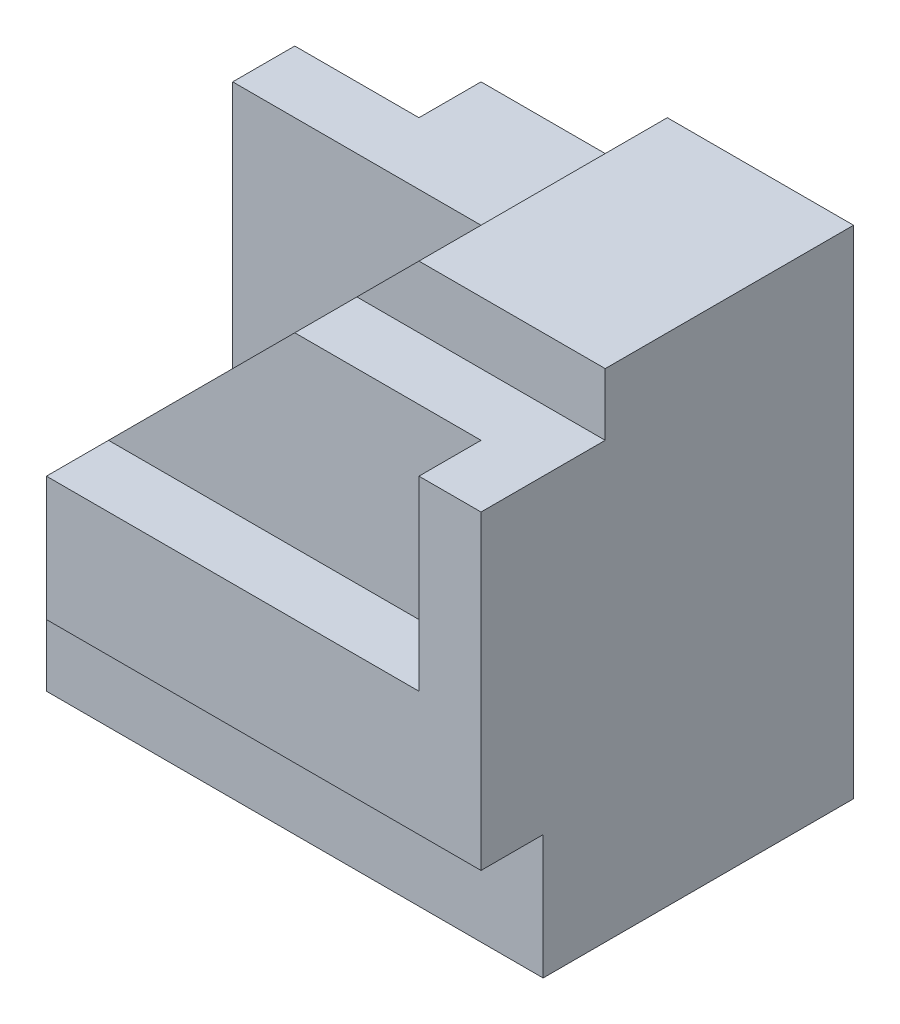
from build123d import *

# Parameters (mm, degrees)
SKETCH1_W           = 8
SKETCH1_H           = 6
BOSS_EXTRUDE1_DEPTH = 8
SKETCH2_W           = 1
SKETCH2_H           = 2
CUT_EXTRUDE1_DEPTH  = 9
SKETCH3_W           = 7
SKETCH3_H           = 4
CUT_EXTRUDE2_DEPTH  = 1
SKETCH4_W           = 3
SKETCH4_H           = 1
CUT_EXTRUDE3_DEPTH  = 2
CUT_EXTRUDE4_DEPTH  = 3
SKETCH8_W           = 1
SKETCH8_H           = 1
CUT_EXTRUDE7_DEPTH  = 1
CUT_EXTRUDE8_DEPTH  = 3
CUT_EXTRUDE9_DEPTH  = 1
SKETCH14_W          = 4
SKETCH14_H          = 2
CUT_EXTRUDE12_DEPTH = 1
BOSS_EXTRUDE2_DEPTH = 1
SKETCH16_W          = 1
SKETCH16_H          = 1
CUT_EXTRUDE13_DEPTH = 5
CUT_EXTRUDE14_DEPTH = 1


with BuildPart() as part:
    # Sketch1 → Boss-Extrude1 (new body)
    with BuildSketch(Plane(origin=(0, 0, 0), x_dir=(1, 0, 0), z_dir=(0, 1, 0))):
        Rectangle(SKETCH1_W, SKETCH1_H)
    extrude(amount=BOSS_EXTRUDE1_DEPTH)

    # Sketch2 → Cut-Extrude1 (cut, through all)
    with BuildSketch(Plane.ZY.offset(4)):
        with Locations((2.5, 1)):
            Rectangle(SKETCH2_W, SKETCH2_H)
    extrude(amount=-CUT_EXTRUDE1_DEPTH, mode=Mode.SUBTRACT)

    # Sketch3 → Cut-Extrude2 (cut)
    with BuildSketch(Plane.XY.offset(3)):
        with Locations((-0.5, 6)):
            Rectangle(SKETCH3_W, SKETCH3_H)
    extrude(amount=-CUT_EXTRUDE2_DEPTH, mode=Mode.SUBTRACT)

    # Sketch4 → Cut-Extrude3 (cut)
    with BuildSketch(Plane.XY.offset(3)):
        with Locations((2.5, 7.5)):
            Rectangle(SKETCH4_W, SKETCH4_H)
    extrude(amount=-CUT_EXTRUDE3_DEPTH, mode=Mode.SUBTRACT)

    # Sketch5 → Cut-Extrude4 (cut)
    with BuildSketch(Plane.XY.offset(2)):
        Polygon((1, 8), (-3, 4), (-4, 4), (-4, 8), align=None)
    extrude(amount=-CUT_EXTRUDE4_DEPTH, mode=Mode.SUBTRACT)

    # Sketch8 → Cut-Extrude7 (cut)
    with BuildSketch(Plane(origin=(1, 0, 0), x_dir=(0, 0, -1), z_dir=(1, 0, 0))):
        with Locations((-1.5, 7.5)):
            Rectangle(SKETCH8_W, SKETCH8_H)
    extrude(amount=-CUT_EXTRUDE7_DEPTH, mode=Mode.SUBTRACT)

    # Sketch9 → Cut-Extrude8 (cut, through all)
    with BuildSketch(Plane.XY.offset(-1)):
        Polygon((0, 8), (1, 8), (0, 7), align=None)
    extrude(amount=-CUT_EXTRUDE8_DEPTH, mode=Mode.SUBTRACT)

    # Sketch10 → Cut-Extrude9 (cut)
    with BuildSketch(Plane(origin=(0, 8, 0), x_dir=(1, 0, 0), z_dir=(0, 1, 0))):
        Polygon((-4, 1), (-4, 2), (-2, 2), (-2, 3), (0, 3), (0, 1), align=None)
    extrude(amount=-CUT_EXTRUDE9_DEPTH, mode=Mode.SUBTRACT)

    # Sketch14 → Cut-Extrude12 (cut)
    with BuildSketch(Plane.ZY.offset(4)):
        with Locations((1, 3)):
            Rectangle(SKETCH14_W, SKETCH14_H)
    extrude(amount=-CUT_EXTRUDE12_DEPTH, mode=Mode.SUBTRACT)

    # Sketch15 → Boss-Extrude2 (add)
    with BuildSketch(Plane.ZY.offset(4)):
        Polygon((-3, 8), (-2, 8), (-2, 7), (-1, 7), (-1, 2), (0, 2), (0, 0), (-3, 0), align=None)
    extrude(amount=BOSS_EXTRUDE2_DEPTH)

    # Sketch16 → Cut-Extrude13 (cut)
    with BuildSketch(Plane(origin=(0, 7, 0), x_dir=(1, 0, 0), z_dir=(0, 1, 0))):
        with Locations((-4.5, 1.5)):
            Rectangle(SKETCH16_W, SKETCH16_H)
    extrude(amount=-CUT_EXTRUDE13_DEPTH, mode=Mode.SUBTRACT)

    # Sketch17 → Cut-Extrude14 (cut)
    with BuildSketch(Plane(origin=(0, 0, -3), x_dir=(-1, 0, 0), z_dir=(0, 0, -1))):
        Polygon((2, 7), (5, 4), (5, 8), (2, 8), align=None)
    extrude(amount=-CUT_EXTRUDE14_DEPTH, mode=Mode.SUBTRACT)


solid = part.part
